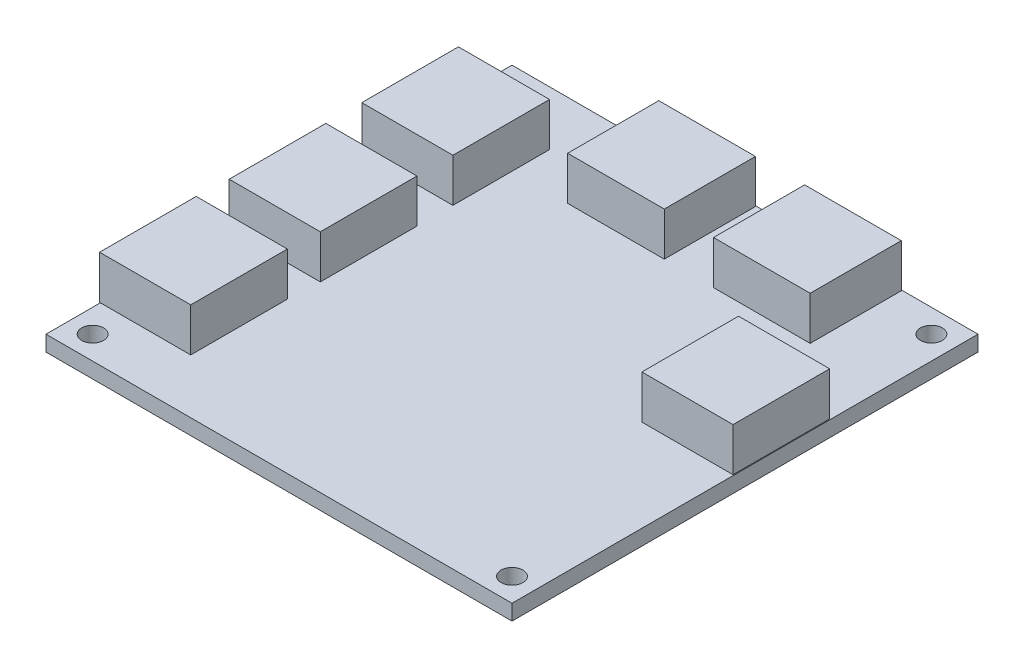
from build123d import *

# Parameters (mm, degrees)
SKETCH1_W                           = 76.2
SKETCH1_H                           = 76.2
BOSS_EXTRUDE1_DEPTH                 = 2.54
SKETCH2_W                           = 14.9
SKETCH2_H                           = 15.8
SKETCH2_W_2                         = 15.8
SKETCH2_H_2                         = 14.9
BOSS_EXTRUDE2_DEPTH                 = 7.1
F_9_64_0_14063_DIAMETER_HOLE1_D     = 3.572002
F_9_64_0_14063_DIAMETER_HOLE1_DEPTH = 5.7404
F_9_64_0_14063_DIAMETER_HOLE1_TIP   = 1.073137666


with BuildPart() as part:
    # Sketch1 → Boss-Extrude1 (new body)
    with BuildSketch(Plane(origin=(0, 0, 0), x_dir=(1, 0, 0), z_dir=(0, 1, 0))):
        Rectangle(SKETCH1_W, SKETCH1_H)
    extrude(amount=BOSS_EXTRUDE1_DEPTH)

    # Sketch2 → Boss-Extrude2 (add)
    with BuildSketch(Plane(origin=(0, 2.54, 0), x_dir=(1, 0, 0), z_dir=(0, 1, 0))):
        with Locations((-30.777, -21.31)):
            Rectangle(SKETCH2_W, SKETCH2_H)
        with Locations((-30.523, 21.31)):
            Rectangle(SKETCH2_W, SKETCH2_H)
        with Locations((-6.07, 30.523)):
            Rectangle(SKETCH2_W_2, SKETCH2_H_2)
        with Locations((17.7818, 30.523)):
            Rectangle(SKETCH2_W_2, SKETCH2_H_2)
        with Locations((30.523, 6.07)):
            Rectangle(SKETCH2_W, SKETCH2_H)
        with Locations((-30.523, -0.372526433)):
            Rectangle(SKETCH2_W, SKETCH2_H)
    extrude(amount=BOSS_EXTRUDE2_DEPTH)

    # 9/64 (0.14063) Diameter Hole1
    with Locations(Plane(origin=(0, 2.54, 0), x_dir=(1, 0, 0), z_dir=(0, 1, 0))):
        with Locations((34.29, -34.29), (-34.29, -34.29), (-34.29, 34.29), (34.29, 34.29)):
            Hole(F_9_64_0_14063_DIAMETER_HOLE1_D / 2, depth=F_9_64_0_14063_DIAMETER_HOLE1_DEPTH)
            with Locations((0, 0, -(F_9_64_0_14063_DIAMETER_HOLE1_DEPTH + F_9_64_0_14063_DIAMETER_HOLE1_TIP / 2))):  # 118° drill point
                Cone(0, F_9_64_0_14063_DIAMETER_HOLE1_D / 2, F_9_64_0_14063_DIAMETER_HOLE1_TIP, mode=Mode.SUBTRACT)


solid = part.part
